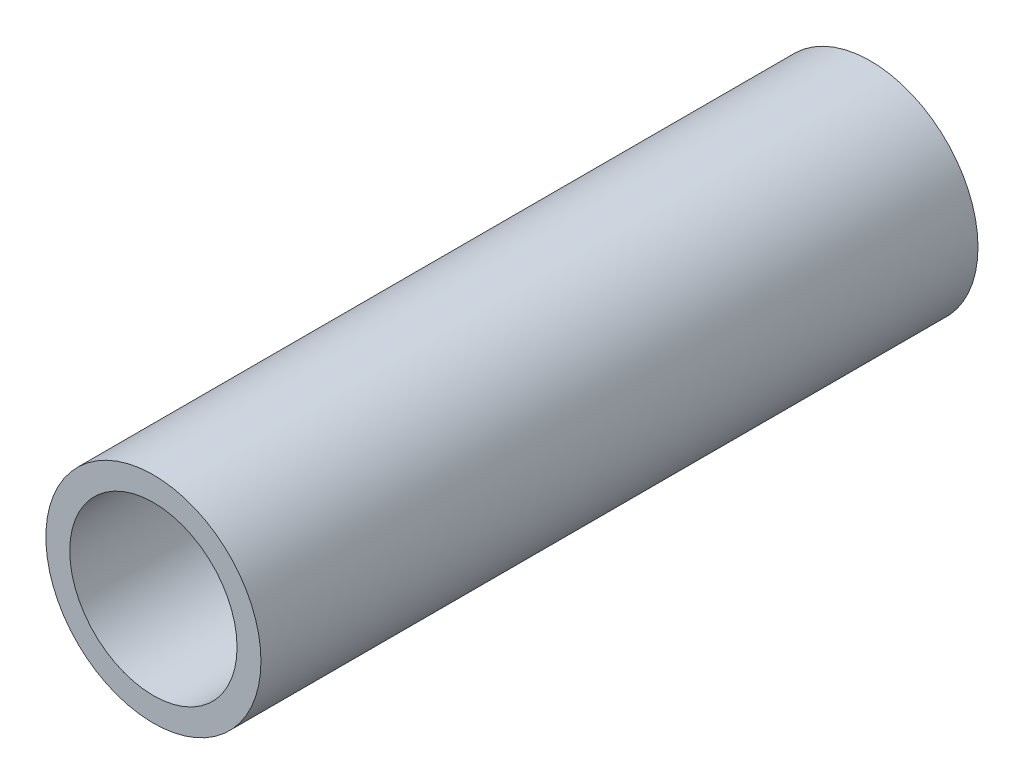
from build123d import *

# Parameters (mm, degrees)
SKETCH1_R           = 2.25
SKETCH1_R_2         = 1.75
BOSS_EXTRUDE1_DEPTH = 15


with BuildPart() as part:
    # Sketch1 → Boss-Extrude1 (new body)
    with BuildSketch(Plane.XY):
        Circle(SKETCH1_R)
        Circle(SKETCH1_R_2, mode=Mode.SUBTRACT)
    extrude(amount=BOSS_EXTRUDE1_DEPTH)


solid = part.part
